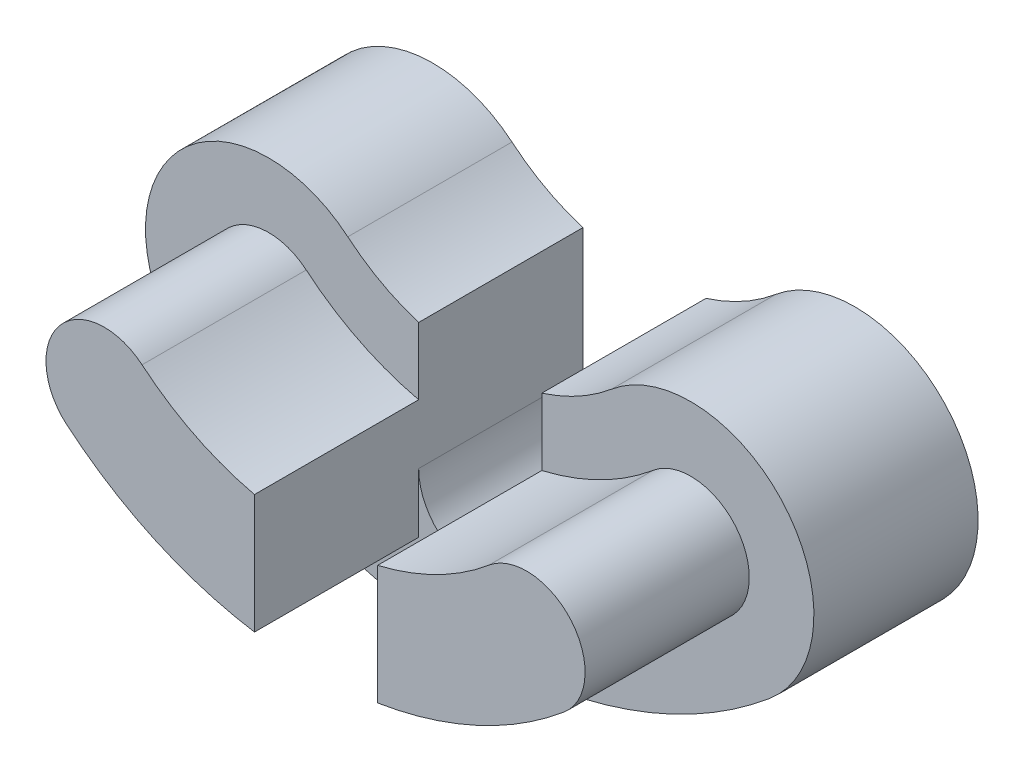
from build123d import *

# Parameters (mm, degrees)
BOSS_EXTRUDE1_DEPTH   = 8
BOSS_EXTRUDE1_2_DEPTH = 8
BOSS_EXTRUDE2_DEPTH   = 8


with BuildPart() as part:
    # Sketch1 → Boss-Extrude1 (new body)
    with BuildSketch(Plane.XY):
        with BuildLine():
            Line((-2.974906864, -18.61376988), (-2.974906864, -12.809076046))
            ThreePointArc((-2.974906864, -12.809076046), (-5.875216569, -11.764536976), (-8.452657067, -10.073484427))
            ThreePointArc((-8.452657067, -10.073484427), (-12.467828418, -10.424766402), (-12.116546443, -14.439937753))
            ThreePointArc((-12.116546443, -14.439937753), (-7.828997981, -17.14728231), (-2.974906864, -18.61376988))
        make_face()
    extrude(amount=BOSS_EXTRUDE1_DEPTH)



with BuildPart() as body_2:
    # Sketch1 → Boss-Extrude1 2 (new body)
    with BuildSketch(Plane.XY):
        with BuildLine():
            ThreePointArc((8.452657067, -10.073484427), (5.898262695, -11.752999497), (3.025093136, -12.797316575))
            Line((3.025093136, -12.797316575), (3.025093136, -18.60567955))
            ThreePointArc((3.025093136, -18.60567955), (7.852112038, -17.136710202), (12.116546443, -14.439937753))
            ThreePointArc((12.116546443, -14.439937753), (12.467828418, -10.424766402), (8.452657067, -10.073484427))
        make_face()
    extrude(amount=BOSS_EXTRUDE1_2_DEPTH)


with BuildPart() as part_1:
    add(part.part)

    add(body_2.part)  # Boss-Extrude2 merges body 2
    # Sketch2 → Boss-Extrude2 (add)
    with BuildSketch(Plane(origin=(0, 0, 0), x_dir=(-1, 0, 0), z_dir=(0, 0, -1))):
        with BuildLine():
            Line((-3.025093136, -15.711422963), (-3.025093136, -12.797316575))
            Line((-3.025093136, -12.797316575), (-3.025093136, -9.53146429))
            ThreePointArc((-3.025093136, -9.53146429), (-4.818177628, -8.762714439), (-6.427876097, -7.660444431))
            ThreePointArc((-6.427876097, -7.660444431), (-14.880868414, -8.399985432), (-14.141327413, -16.852977749))
            ThreePointArc((-14.141327413, -16.852977749), (0, -22), (14.141327413, -16.852977749))
            ThreePointArc((14.141327413, -16.852977749), (14.880868414, -8.399985432), (6.427876097, -7.660444431))
            ThreePointArc((6.427876097, -7.660444431), (4.795110846, -8.775358225), (2.974906864, -9.547247203))
            Line((2.974906864, -9.547247203), (2.974906864, -12.809076046))
            ThreePointArc((2.974906864, -12.809076046), (5.875216569, -11.764536976), (8.452657067, -10.073484427))
            ThreePointArc((8.452657067, -10.073484427), (12.467828418, -10.424766402), (12.116546443, -14.439937753))
            ThreePointArc((12.116546443, -14.439937753), (7.828997981, -17.14728231), (2.974906864, -18.61376988))
            Line((2.974906864, -18.61376988), (2.974906864, -15.711422963))
            ThreePointArc((2.974906864, -15.711422963), (-0.025093136, -18.711422963), (-3.025093136, -15.711422963))
        make_face()
        with BuildLine():
            ThreePointArc((12.116546443, -14.439937753), (12.467828418, -10.424766402), (8.452657067, -10.073484427))
            ThreePointArc((8.452657067, -10.073484427), (5.875216569, -11.764536976), (2.974906864, -12.809076046))
            Line((2.974906864, -12.809076046), (2.974906864, -18.61376988))
            ThreePointArc((2.974906864, -18.61376988), (7.828997981, -17.14728231), (12.116546443, -14.439937753))
        make_face()
    extrude(amount=BOSS_EXTRUDE2_DEPTH)


solid = part_1.part
